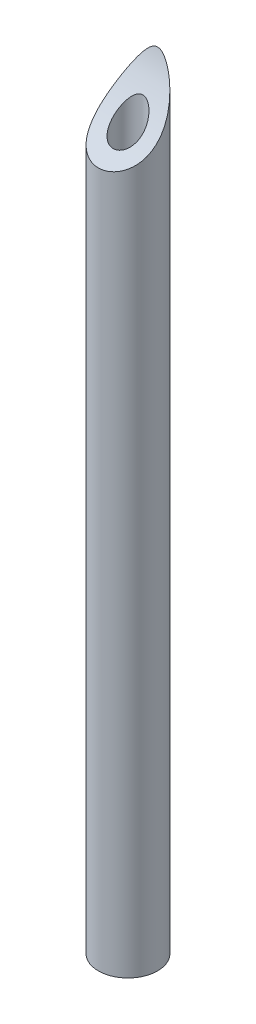
from build123d import *

# Parameters (mm, degrees)
SKETCH1_R           = 2
SKETCH1_R_2         = 1
BOSS_EXTRUDE1_DEPTH = 26
SKETCH2_R           = 8
CUT_EXTRUDE1_DEPTH  = 2


with BuildPart() as part:
    # Sketch1 → Boss-Extrude1 (new body, symmetric)
    with BuildSketch(Plane(origin=(0, 0, 0), x_dir=(1, 0, 0), z_dir=(0, 1, 0))):
        Circle(SKETCH1_R)
        Circle(SKETCH1_R_2, mode=Mode.SUBTRACT)
    extrude(amount=BOSS_EXTRUDE1_DEPTH, both=True)

    # Sketch2 → Cut-Extrude1 (cut, symmetric)
    with BuildSketch(Plane(origin=(0, 0, 0), x_dir=(0, 0, -1), z_dir=(1, 0, 0))):
        with Locations((-5.745966692, 28)):
            Circle(SKETCH2_R)
    extrude(amount=CUT_EXTRUDE1_DEPTH, both=True, mode=Mode.SUBTRACT)


solid = part.part
